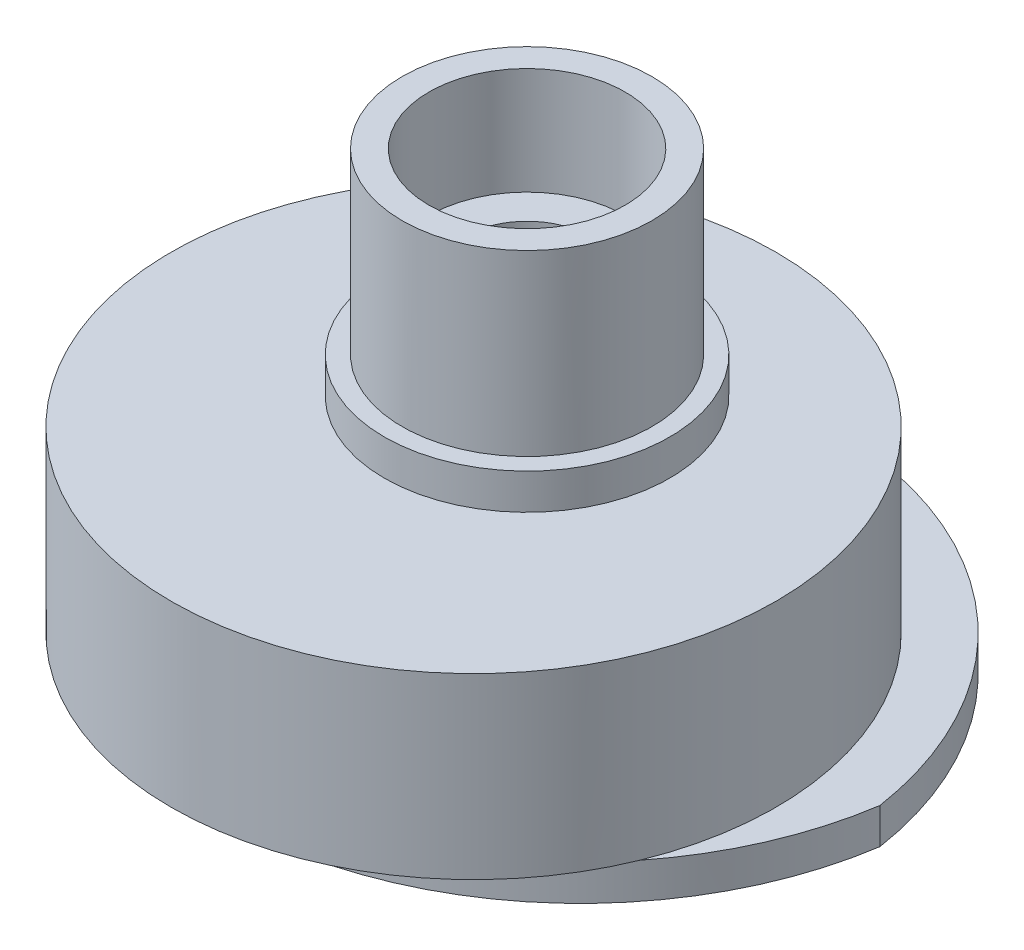
from build123d import *

# Parameters (mm, degrees)
SKETCH1_R           = 3.5
SKETCH1_R_2         = 2.75
BOSS_EXTRUDE1_DEPTH = 3
SKETCH2_R           = 3.5
SKETCH2_R_2         = 1.75
BOSS_EXTRUDE2_DEPTH = 2
SKETCH3_R           = 4
SKETCH3_R_2         = 1.75
BOSS_EXTRUDE3_DEPTH = 1
SKETCH4_R           = 8.475
SKETCH4_R_2         = 1.75
BOSS_EXTRUDE4_DEPTH = 5
SKETCH5_R           = 1.75
BOSS_EXTRUDE5_DEPTH = 1
SKETCH6_W           = 9.3
SKETCH6_H           = 6.3
CUT_EXTRUDE1_DEPTH  = 5


with BuildPart() as part:
    # Sketch1 → Boss-Extrude1 (new body)
    with BuildSketch(Plane(origin=(0, 0, 0), x_dir=(1, 0, 0), z_dir=(0, 1, 0))):
        Circle(SKETCH1_R)
        Circle(SKETCH1_R_2, mode=Mode.SUBTRACT)
    extrude(amount=BOSS_EXTRUDE1_DEPTH)

    # Sketch2 → Boss-Extrude2 (add)
    with BuildSketch(Plane(origin=(0, 0, 0), x_dir=(-1, 0, 0), z_dir=(0, -1, 0))):
        Circle(SKETCH2_R)
        Circle(SKETCH2_R_2, mode=Mode.SUBTRACT)
    extrude(amount=BOSS_EXTRUDE2_DEPTH)

    # Sketch3 → Boss-Extrude3 (add)
    with BuildSketch(Plane(origin=(0, -2, 0), x_dir=(-1, 0, 0), z_dir=(0, -1, 0))):
        Circle(SKETCH3_R)
        Circle(SKETCH3_R_2, mode=Mode.SUBTRACT)
    extrude(amount=BOSS_EXTRUDE3_DEPTH)

    # Sketch4 → Boss-Extrude4 (add)
    with BuildSketch(Plane(origin=(0, -3, 0), x_dir=(-1, 0, 0), z_dir=(0, -1, 0))):
        with Locations((0, -1.5)):
            Circle(SKETCH4_R)
        Circle(SKETCH4_R_2, mode=Mode.SUBTRACT)
    extrude(amount=BOSS_EXTRUDE4_DEPTH)

    # Sketch5 → Boss-Extrude5 (add)
    with BuildSketch(Plane(origin=(0, -8, 0), x_dir=(-1, 0, 0), z_dir=(0, -1, 0))):
        with BuildLine():
            ThreePointArc((-9.886859967, 0), (0, -8.5), (9.886859967, 0))
            ThreePointArc((9.886859967, 0), (0, 8.5), (-9.886859967, 0))
        make_face()
        Circle(SKETCH5_R, mode=Mode.SUBTRACT)
    extrude(amount=BOSS_EXTRUDE5_DEPTH)

    # Sketch6 → Cut-Extrude1 (cut)
    with BuildSketch(Plane(origin=(0, -9, 0), x_dir=(-1, 0, 0), z_dir=(0, -1, 0))):
        Rectangle(SKETCH6_W, SKETCH6_H)
    extrude(amount=-CUT_EXTRUDE1_DEPTH, mode=Mode.SUBTRACT)


solid = part.part
